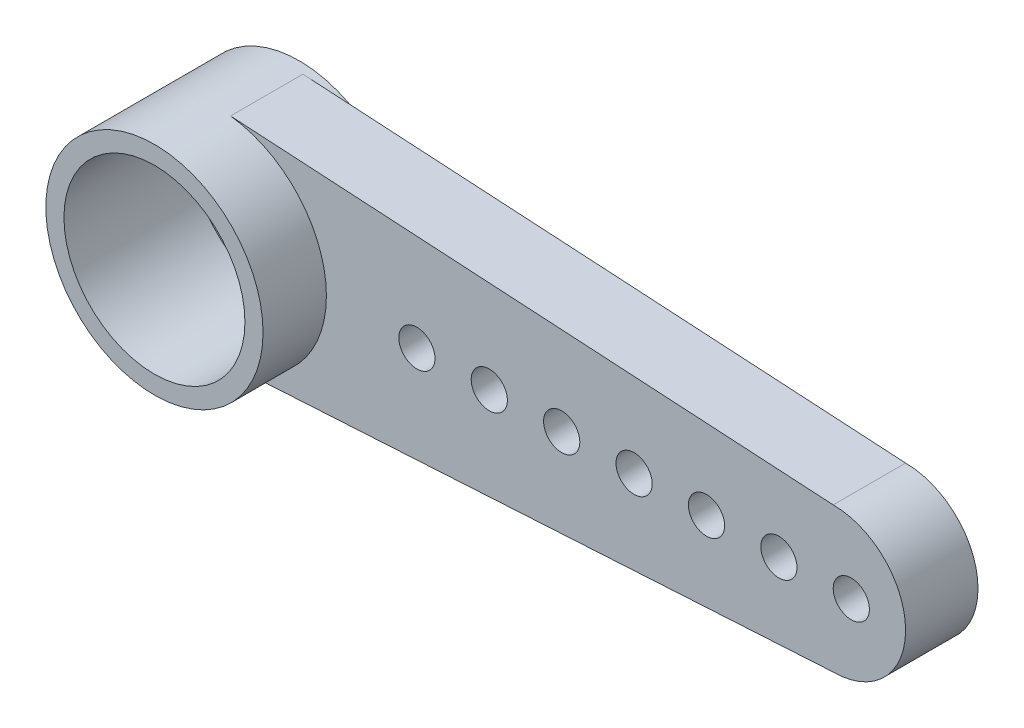
from build123d import *

# Parameters (mm, degrees)
SKETCH_1_R          = 3
EXTRUDE_1_DEPTH     = 4
SKETCH_6_R          = 0.5
EXTRUDE_2_DEPTH     = 2
SKETCH_3_R          = 2
CUT_EXTRUDE_2_DEPTH = 0.25
SKETCH_4_R          = 1.25
CUT_EXTRUDE_3_DEPTH = 4.75
SKETCH_2_R          = 2.5
CUT_EXTRUDE_1_DEPTH = 3.5


with BuildPart() as part:
    # 草图1 → 凸台-拉伸1 (new body)
    with BuildSketch(Plane.XY):
        Circle(SKETCH_1_R)
    extrude(amount=EXTRUDE_1_DEPTH)

    # 草图6 → 凸台-拉伸2 (add)
    with BuildSketch(Plane(origin=(0, 0, 0.25), x_dir=(-1, 0, 0), z_dir=(0, 0, -1))):
        with BuildLine():
            Line((-17, 2), (0, 3))
            Line((0, 3), (0, -3))
            Line((0, -3), (-17, -2))
            ThreePointArc((-17, -2), (-19, 0), (-17, 2))
        make_face()
        with Locations((-17.5, 0)):
            Circle(SKETCH_6_R, mode=Mode.SUBTRACT)
        with Locations((-15.5, 0)):
            Circle(SKETCH_6_R, mode=Mode.SUBTRACT)
        with Locations((-13.5, 0)):
            Circle(SKETCH_6_R, mode=Mode.SUBTRACT)
        with Locations((-11.5, 0)):
            Circle(SKETCH_6_R, mode=Mode.SUBTRACT)
        with Locations((-9.5, 0)):
            Circle(SKETCH_6_R, mode=Mode.SUBTRACT)
        with Locations((-7.5, 0)):
            Circle(SKETCH_6_R, mode=Mode.SUBTRACT)
        with Locations((-5.5, 0)):
            Circle(SKETCH_6_R, mode=Mode.SUBTRACT)
    extrude(amount=-EXTRUDE_2_DEPTH)

    # 草图3 → 切除-拉伸2 (cut)
    with BuildSketch(Plane(origin=(0, 0, 0), x_dir=(-1, 0, 0), z_dir=(0, 0, -1))):
        Circle(SKETCH_3_R)
    extrude(amount=-CUT_EXTRUDE_2_DEPTH, mode=Mode.SUBTRACT)

    # 草图4 → 切除-拉伸3 (cut, through all)
    with BuildSketch(Plane(origin=(0, 0, 0.25), x_dir=(-1, 0, 0), z_dir=(0, 0, -1))):
        Circle(SKETCH_4_R)
    extrude(amount=-CUT_EXTRUDE_3_DEPTH, mode=Mode.SUBTRACT)

    # 草图2 → 切除-拉伸1 (cut)
    with BuildSketch(Plane.XY.offset(4)):
        Circle(SKETCH_2_R)
    extrude(amount=-CUT_EXTRUDE_1_DEPTH, mode=Mode.SUBTRACT)


solid = part.part
